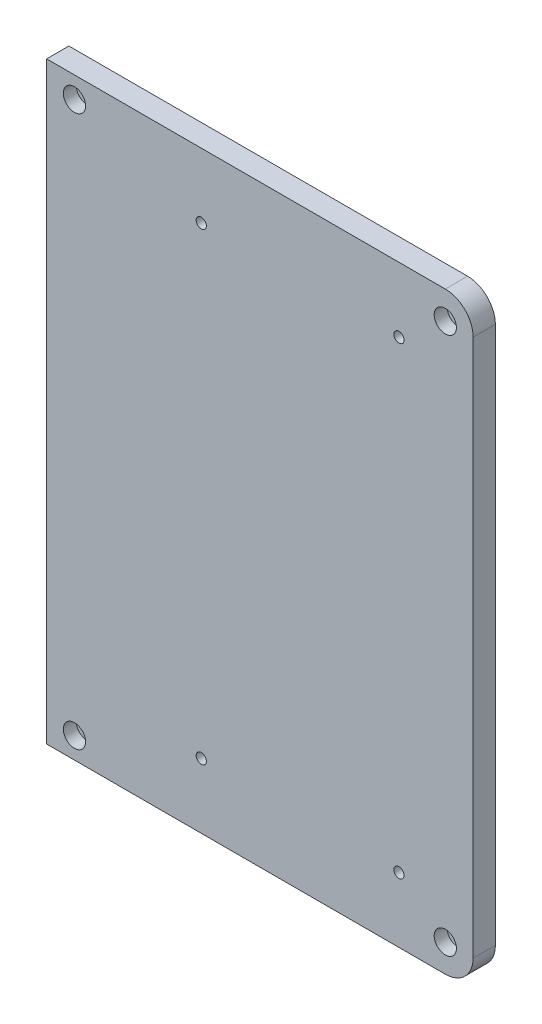
from build123d import *

# Parameters (mm, degrees)
BOSS_EXTRUDE1_DEPTH     = 6
SKETCH2_R               = 1.75
CUT_EXTRUDE1_DEPTH      = 10
SKETCH3_R               = 3
CUT_EXTRUDE2_DEPTH      = 3.5
SKETCH4_R               = 1.5
CUT_EXTRUDE3_DEPTH      = 7
SKETCH5_R               = 1.375
CUT_EXTRUDE4_DEPTH      = 1
CUT_EXTRUDE4_DEPTH_BACK = 7
SKETCH7_R               = 1.5
CUT_EXTRUDE6_DEPTH      = 7
SKETCH8_R               = 3
CUT_EXTRUDE7_DEPTH      = 3.5
SKETCH9_W               = 115
SKETCH9_H               = 160
CUT_EXTRUDE8_DEPTH      = 10
SKETCH10_R              = 1.75
CUT_EXTRUDE9_DEPTH      = 6
SKETCH14_R              = 3
CUT_EXTRUDE10_DEPTH     = 3.5
SKETCH16_R              = 1.75
CUT_EXTRUDE11_DEPTH     = 6
SKETCH17_R              = 3
CUT_EXTRUDE12_DEPTH     = 3.5


with BuildPart() as part:
    # Sketch1 → Boss-Extrude1 (new body)
    with BuildSketch(Plane.XY):
        with BuildLine():
            Line((-107.5, 80), (107.5, 80))
            ThreePointArc((107.5, 80), (112.803300859, 77.803300859), (115, 72.5))
            Line((115, 72.5), (115, -72.5))
            ThreePointArc((115, -72.5), (112.803300859, -77.803300859), (107.5, -80))
            Line((107.5, -80), (-107.5, -80))
            ThreePointArc((-107.5, -80), (-112.803300859, -77.803300859), (-115, -72.5))
            Line((-115, -72.5), (-115, 72.5))
            ThreePointArc((-115, 72.5), (-112.803300859, 77.803300859), (-107.5, 80))
        make_face()
    extrude(amount=BOSS_EXTRUDE1_DEPTH)

    # Sketch2 → Cut-Extrude1 (cut)
    with BuildSketch(Plane.XY.offset(6)):
        with Locations((-107.5, -72.5)):
            Circle(SKETCH2_R)
        with Locations((-107.5, 72.5)):
            Circle(SKETCH2_R)
        with Locations((107.5, -72.5)):
            Circle(SKETCH2_R)
        with Locations((107.5, 72.5)):
            Circle(SKETCH2_R)
    extrude(amount=-CUT_EXTRUDE1_DEPTH, mode=Mode.SUBTRACT)

    # Sketch3 → Cut-Extrude2 (cut)
    with BuildSketch(Plane.XY.offset(6)):
        with Locations((-107.5, -72.5)):
            Circle(SKETCH3_R)
        with Locations((-107.5, 72.5)):
            Circle(SKETCH3_R)
        with Locations((107.5, 72.5)):
            Circle(SKETCH3_R)
        with Locations((107.5, -72.5)):
            Circle(SKETCH3_R)
    extrude(amount=-CUT_EXTRUDE2_DEPTH, mode=Mode.SUBTRACT)

    # Sketch4 → Cut-Extrude3 (cut, through all)
    with BuildSketch(Plane.XY.offset(6)):
        with Locations((-96.5, 37.5)):
            Circle(SKETCH4_R)
        with Locations((-96.5, -37.5)):
            Circle(SKETCH4_R)
        with Locations((-24.5, 37.5)):
            Circle(SKETCH4_R)
        with Locations((-24.5, -37.5)):
            Circle(SKETCH4_R)
    extrude(amount=-CUT_EXTRUDE3_DEPTH, mode=Mode.SUBTRACT)

    # Sketch5 → Cut-Extrude4 (cut, two sides)
    with BuildSketch(Plane.XY.offset(6)) as cut_extrude4_sk:
        with Locations((95, -62.5)):
            Circle(SKETCH5_R)
        with Locations((95, 62.5)):
            Circle(SKETCH5_R)
        with Locations((41.7, -62.5)):
            Circle(SKETCH5_R)
        with Locations((41.7, 62.5)):
            Circle(SKETCH5_R)
    extrude(amount=CUT_EXTRUDE4_DEPTH, mode=Mode.SUBTRACT)
    extrude(cut_extrude4_sk.sketch, amount=-CUT_EXTRUDE4_DEPTH_BACK, mode=Mode.SUBTRACT)

    # Sketch7 → Cut-Extrude6 (cut, through all)
    with BuildSketch(Plane.XY.offset(6)):
        with Locations((-102.8, 42.3)):
            Circle(SKETCH7_R)
        with Locations((-102.8, -42.3)):
            Circle(SKETCH7_R)
        with Locations((-18.2, -42.3)):
            Circle(SKETCH7_R)
        with Locations((-18.2, 42.3)):
            Circle(SKETCH7_R)
    extrude(amount=-CUT_EXTRUDE6_DEPTH, mode=Mode.SUBTRACT)

    # Sketch8 → Cut-Extrude7 (cut)
    with BuildSketch(Plane(origin=(0, 0, 0), x_dir=(-1, 0, 0), z_dir=(0, 0, -1))):
        with Locations((18.2, 42.3)):
            Circle(SKETCH8_R)
        with Locations((18.2, -42.3)):
            Circle(SKETCH8_R)
        with Locations((102.8, -42.3)):
            Circle(SKETCH8_R)
        with Locations((102.8, 42.3)):
            Circle(SKETCH8_R)
    extrude(amount=-CUT_EXTRUDE7_DEPTH, mode=Mode.SUBTRACT)

    # Sketch9 → Cut-Extrude8 (cut)
    with BuildSketch(Plane.XY.offset(6)):
        with Locations((-57.5, 0)):
            Rectangle(SKETCH9_W, SKETCH9_H)
    extrude(amount=-CUT_EXTRUDE8_DEPTH, mode=Mode.SUBTRACT)

    # Sketch10 → Cut-Extrude9 (cut)
    with BuildSketch(Plane.XY.offset(6)):
        with Locations((7.5, -74.25)):
            Circle(SKETCH10_R)
    extrude(amount=-CUT_EXTRUDE9_DEPTH, mode=Mode.SUBTRACT)

    # Sketch14 → Cut-Extrude10 (cut)
    with BuildSketch(Plane.XY.offset(6)):
        with Locations((7.5, -74.25)):
            Circle(SKETCH14_R)
    extrude(amount=-CUT_EXTRUDE10_DEPTH, mode=Mode.SUBTRACT)

    # Sketch16 → Cut-Extrude11 (cut)
    with BuildSketch(Plane.XY.offset(6)):
        with Locations((7.5, 74.25)):
            Circle(SKETCH16_R)
    extrude(amount=-CUT_EXTRUDE11_DEPTH, mode=Mode.SUBTRACT)

    # Sketch17 → Cut-Extrude12 (cut)
    with BuildSketch(Plane.XY.offset(6)):
        with Locations((7.5, 74.25)):
            Circle(SKETCH17_R)
    extrude(amount=-CUT_EXTRUDE12_DEPTH, mode=Mode.SUBTRACT)


solid = part.part
